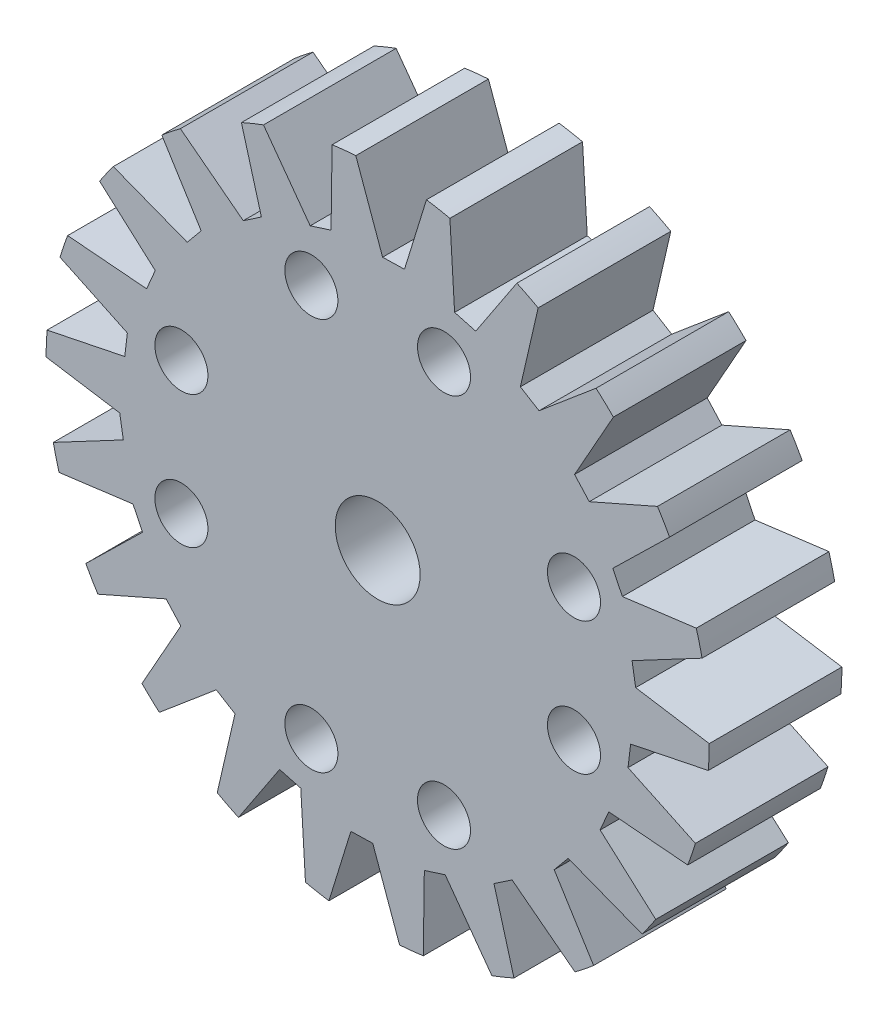
from build123d import *

# Parameters (mm, degrees)
SKETCH1_R           = 12.5
SKETCH1_R_2         = 1.6
SKETCH1_R_3         = 1
BOSS_EXTRUDE1_DEPTH = 5
CUT_EXTRUDE1_DEPTH  = 6
CIRPATTERN1_COUNT   = 22


with BuildPart() as part:
    # Sketch1 → Boss-Extrude1 (new body)
    with BuildSketch(Plane.XY):
        Circle(SKETCH1_R)
        Circle(SKETCH1_R_2, mode=Mode.SUBTRACT)
        with Locations((-2.5, 7.4)):
            Circle(SKETCH1_R_3, mode=Mode.SUBTRACT)
        with Locations((2.5, 7.4)):
            Circle(SKETCH1_R_3, mode=Mode.SUBTRACT)
        with Locations((2.5, -7.4)):
            Circle(SKETCH1_R_3, mode=Mode.SUBTRACT)
        with Locations((-2.5, -7.4)):
            Circle(SKETCH1_R_3, mode=Mode.SUBTRACT)
        with Locations((7.4, -2.5)):
            Circle(SKETCH1_R_3, mode=Mode.SUBTRACT)
        with Locations((7.4, 2.5)):
            Circle(SKETCH1_R_3, mode=Mode.SUBTRACT)
        with Locations((-7.4, 2.5)):
            Circle(SKETCH1_R_3, mode=Mode.SUBTRACT)
        with Locations((-7.4, -2.5)):
            Circle(SKETCH1_R_3, mode=Mode.SUBTRACT)
    extrude(amount=BOSS_EXTRUDE1_DEPTH)

    # Sketch2 → Cut-Extrude1 (cut, through all)
    with BuildSketch(Plane.XY.offset(5)):
        Polygon((-5.188791036, 11.579242099), (-7.447104706, 10.054235749), (-5.067298356, 8.22762092), (-4.383588712, 8.68932009), align=None)
    cut_extrude1 = extrude(amount=-CUT_EXTRUDE1_DEPTH, mode=Mode.SUBTRACT)

    # CirPattern1: Cut-Extrude1 ×22 about axis
    cirpattern1_axis = Axis((0, 0, 0), (0, 0, 1))
    for i in range(1, CIRPATTERN1_COUNT):
        add(cut_extrude1.rotate(cirpattern1_axis, i * 360 / CIRPATTERN1_COUNT), mode=Mode.SUBTRACT)


solid = part.part
